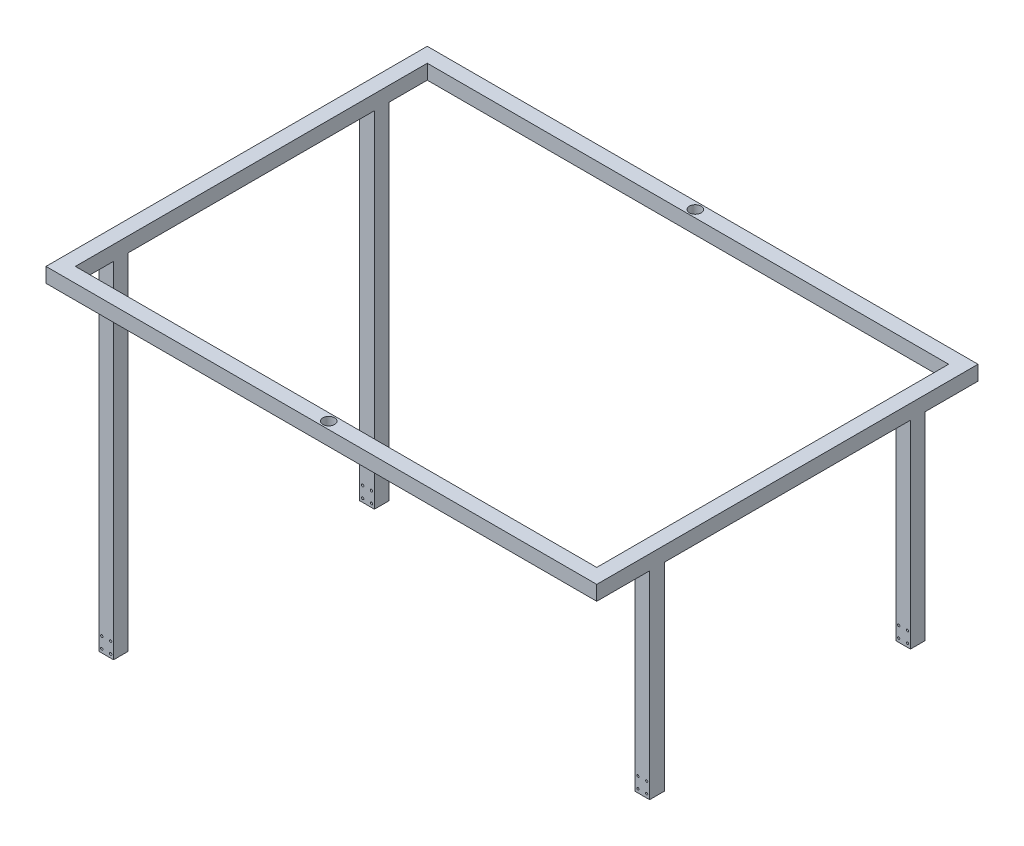
from build123d import *

# Parameters (mm, degrees)
SKETCH_1_W      = 750
SKETCH_1_H      = 519.2
SKETCH_1_W_2    = 710
SKETCH_1_H_2    = 479.2
EXTRUDE_1_DEPTH = 20
SKETCH_2_W      = 20
SKETCH_2_H      = 20
EXTRUDE_2_DEPTH = 470
SKETCH_6_W      = 20
SKETCH_6_H      = 20
EXTRUDE_4_DEPTH = 270
SKETCH_4_R      = 1.6
EXTRUDE1_DEPTH  = 30
SKETCH_7_R      = 1.5
EXTRUDE2_DEPTH  = 30
SKETCH1_R       = 8
EXTRUDE3_DEPTH  = 20


with BuildPart() as part:
    # 草图1 → 凸台-拉伸1 (new body)
    with BuildSketch(Plane(origin=(0, 0, 0), x_dir=(1, 0, 0), z_dir=(0, 1, 0))):
        with Locations((-25.365803698, -25.141816005)):
            Rectangle(SKETCH_1_W, SKETCH_1_H)
        with Locations((-25.365803698, -25.141816005)):
            Rectangle(SKETCH_1_W_2, SKETCH_1_H_2, mode=Mode.SUBTRACT)
    extrude(amount=EXTRUDE_1_DEPTH)

    # 草图2 → 凸台-拉伸2 (add)
    with BuildSketch(Plane.XZ):
        with Locations((-390.365803698, 202.741816005)):
            Rectangle(SKETCH_2_W, SKETCH_2_H)
    extrude_2 = extrude(amount=EXTRUDE_2_DEPTH)

    # 草图6 → 凸台-拉伸4 (add)
    with BuildSketch(Plane.XZ):
        with Locations((339.634196302, -152.458183995)):
            Rectangle(SKETCH_6_W, SKETCH_6_H)
    extrude_4 = extrude(amount=EXTRUDE_4_DEPTH)

    # 草图4 → Extrude1 (cut)
    with BuildSketch(Plane.XY.offset(212.741816005)):
        with Locations((-396.365803698, -465)):
            Circle(SKETCH_4_R)
        with Locations((-384.365803698, -465)):
            Circle(SKETCH_4_R)
        with Locations((-396.365803698, -450)):
            Circle(SKETCH_4_R)
        with Locations((-384.365803698, -450)):
            Circle(SKETCH_4_R)
    extrude1 = extrude(amount=-EXTRUDE1_DEPTH, mode=Mode.SUBTRACT)

    # 草图7 → Extrude2 (cut)
    with BuildSketch(Plane(origin=(0, 0, -162.458183995), x_dir=(-1, 0, 0), z_dir=(0, 0, -1))):
        with Locations((-345.634196302, -265)):
            Circle(SKETCH_7_R)
        with Locations((-333.634196302, -265)):
            Circle(SKETCH_7_R)
        with Locations((-345.634196302, -250)):
            Circle(SKETCH_7_R)
        with Locations((-333.634196302, -250)):
            Circle(SKETCH_7_R)
    extrude2 = extrude(amount=-EXTRUDE2_DEPTH, mode=Mode.SUBTRACT)

    # Mirror1: 凸台-拉伸2, 凸台-拉伸4, Extrude1, Extrude2 across plane
    add(extrude_2.mirror(Plane.XY.offset(25.141816005)))
    add(extrude_4.mirror(Plane.XY.offset(25.141816005)))
    add(extrude1.mirror(Plane.XY.offset(25.141816005)), mode=Mode.SUBTRACT)
    add(extrude2.mirror(Plane.XY.offset(25.141816005)), mode=Mode.SUBTRACT)

    # Sketch1 → Extrude3 (cut)
    with BuildSketch(Plane(origin=(0, 20, 0), x_dir=(1, 0, 0), z_dir=(0, 1, 0))):
        with Locations((-25.365803698, 224.458183995)):
            Circle(SKETCH1_R)
        with Locations((-25.365803698, -274.741816005)):
            Circle(SKETCH1_R)
    extrude(amount=-EXTRUDE3_DEPTH, mode=Mode.SUBTRACT)


solid = part.part
